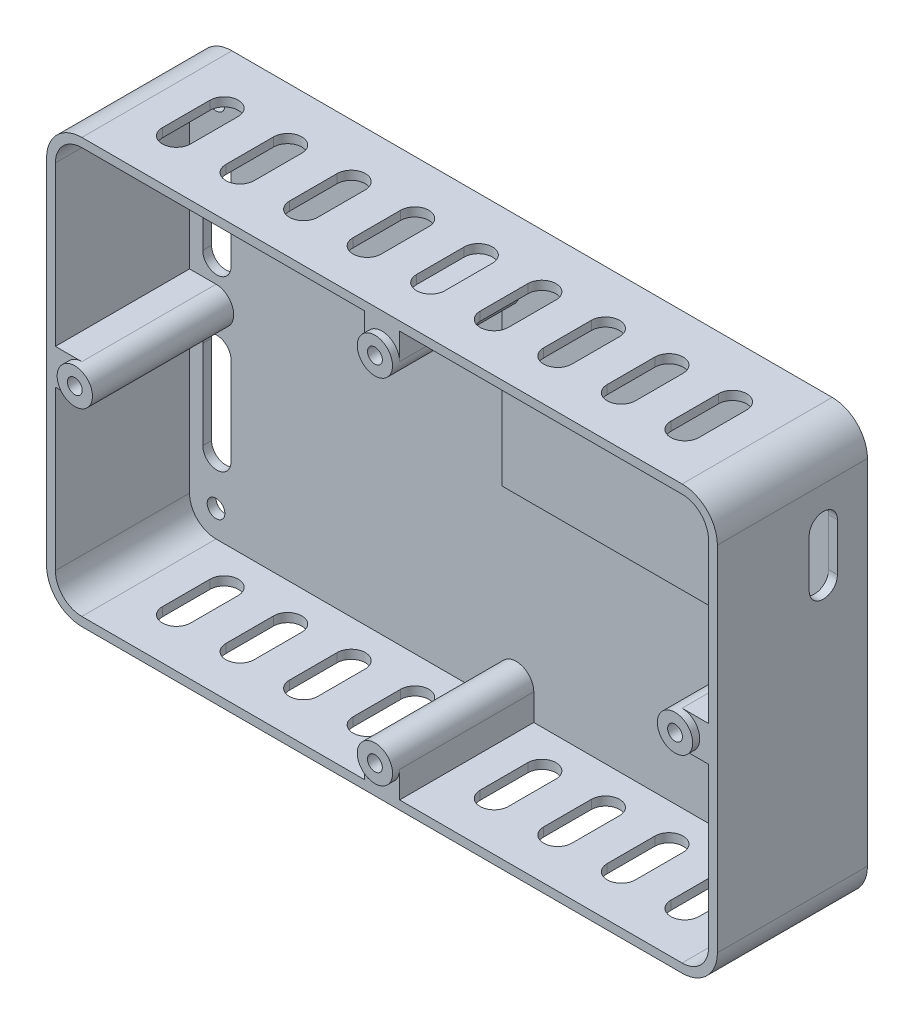
from build123d import *

# Parameters (mm, degrees)
SKETCH1_R                    = 5.975914464
SKETCH1_R_2                  = 5.5
BOSS_EXTRUDE1_DEPTH          = 2
BOSS_EXTRUDE2_DEPTH          = 2.5
SKETCH3_R                    = 5
BOSS_EXTRUDE3_DEPTH          = 38
SKETCH5_R                    = 5
BOSS_EXTRUDE4_DEPTH          = 2
CUT_EXTRUDE1_DEPTH           = 5
TAP_DRILL_FOR_M5_TAP2_D      = 4.2
TAP_DRILL_FOR_M5_TAP2_DEPTH  = 20
TAP_DRILL_FOR_M5_TAP2_TIP    = 1.2618073
F_5_0_5_DIAMETER_HOLE1_D     = 5
F_5_0_5_DIAMETER_HOLE1_DEPTH = 2.5
F_5_0_5_DIAMETER_HOLE1_TIP   = 1.502151548
CUT_EXTRUDE7_DEPTH           = 2.5
BOSS_EXTRUDE5_DEPTH          = 4
CUT_EXTRUDE8_DEPTH           = 2.5
CUT_EXTRUDE9_DEPTH           = 2.5


with BuildPart() as part:
    # Sketch1 → Boss-Extrude1 (new body)
    with BuildSketch(Plane.XY):
        with BuildLine():
            ThreePointArc((-95.175936119, -194.891398577), (-92.247003931, -201.962466389), (-85.175936119, -204.891398577))
            Line((-85.175936119, -204.891398577), (84.824063881, -204.891398577))
            ThreePointArc((84.824063881, -204.891398577), (91.895131693, -201.962466389), (94.824063881, -194.891398577))
            Line((94.824063881, -194.891398577), (94.824063881, -94.891398577))
            ThreePointArc((94.824063881, -94.891398577), (91.895131693, -87.820330766), (84.824063881, -84.891398577))
            Line((84.824063881, -84.891398577), (-85.175936119, -84.891398577))
            ThreePointArc((-85.175936119, -84.891398577), (-92.247003931, -87.820330766), (-95.175936119, -94.891398577))
            Line((-95.175936119, -94.891398577), (-95.175936119, -194.891398577))
        make_face()
        with Locations((84.824063881, -194.891398577)):
            Circle(SKETCH1_R, mode=Mode.SUBTRACT)
        with Locations((-85.175936119, -94.891398577)):
            Circle(SKETCH1_R_2, mode=Mode.SUBTRACT)
        with BuildLine():
            Line((92.324063881, -94.891398577), (92.324063881, -194.891398577))
            ThreePointArc((92.324063881, -194.891398577), (79.520763022, -189.588097719), (84.824063881, -202.391398577))
            Line((84.824063881, -202.391398577), (-85.175936119, -202.391398577))
            ThreePointArc((-85.175936119, -202.391398577), (-79.87263526, -189.588097719), (-92.675936119, -194.891398577))
            Line((-92.675936119, -194.891398577), (-92.675936119, -94.891398577))
            ThreePointArc((-92.675936119, -94.891398577), (-79.87263526, -100.194699436), (-85.175936119, -87.391398577))
            Line((-85.175936119, -87.391398577), (84.824063881, -87.391398577))
            ThreePointArc((84.824063881, -87.391398577), (79.520763022, -100.194699436), (92.324063881, -94.891398577))
        make_face(mode=Mode.SUBTRACT)
        with Locations((84.824063881, -94.891398577)):
            Circle(SKETCH1_R, mode=Mode.SUBTRACT)
        with Locations((-85.175936119, -194.891398577)):
            Circle(SKETCH1_R, mode=Mode.SUBTRACT)
    extrude(amount=BOSS_EXTRUDE1_DEPTH)

    # Sketch2 → Boss-Extrude2 (add)
    with BuildSketch(Plane.XY.offset(2)):
        with BuildLine():
            Line((-95.175936119, -94.891398577), (-95.175936119, -194.891398577))
            ThreePointArc((-95.175936119, -194.891398577), (-92.247003931, -201.962466389), (-85.175936119, -204.891398577))
            Line((-85.175936119, -204.891398577), (84.824063881, -204.891398577))
            ThreePointArc((84.824063881, -204.891398577), (91.895131693, -201.962466389), (94.824063881, -194.891398577))
            Line((94.824063881, -194.891398577), (94.824063881, -94.891398577))
            ThreePointArc((94.824063881, -94.891398577), (91.895131693, -87.820330766), (84.824063881, -84.891398577))
            Line((84.824063881, -84.891398577), (-85.175936119, -84.891398577))
            ThreePointArc((-85.175936119, -84.891398577), (-92.247003931, -87.820330766), (-95.175936119, -94.891398577))
        make_face()
    extrude(amount=BOSS_EXTRUDE2_DEPTH)

    # Sketch3 → Boss-Extrude3 (add)
    with BuildSketch(Plane.XY.offset(4.5)):
        with BuildLine():
            Line((84.824063881, -84.891398577), (-85.175936119, -84.891398577))
            ThreePointArc((-85.175936119, -84.891398577), (-92.247003931, -87.820330766), (-95.175936119, -94.891398577))
            Line((-95.175936119, -94.891398577), (-95.175936119, -194.891398577))
            ThreePointArc((-95.175936119, -194.891398577), (-92.247003931, -201.962466389), (-85.175936119, -204.891398577))
            Line((-85.175936119, -204.891398577), (84.824063881, -204.891398577))
            ThreePointArc((84.824063881, -204.891398577), (91.895131693, -201.962466389), (94.824063881, -194.891398577))
            Line((94.824063881, -194.891398577), (94.824063881, -94.891398577))
            ThreePointArc((94.824063881, -94.891398577), (91.895131693, -87.820330766), (84.824063881, -84.891398577))
        make_face()
        with BuildLine():
            ThreePointArc((92.324063881, -94.891398577), (90.12736474, -89.588097719), (84.824063881, -87.391398577))
            Line((84.824063881, -87.391398577), (-85.175936119, -87.391398577))
            ThreePointArc((-85.175936119, -87.391398577), (-90.479236978, -89.588097719), (-92.675936119, -94.891398577))
            Line((-92.675936119, -94.891398577), (-92.675936119, -194.891398577))
            ThreePointArc((-92.675936119, -194.891398577), (-90.479236978, -200.194699436), (-85.175936119, -202.391398577))
            Line((-85.175936119, -202.391398577), (84.824063881, -202.391398577))
            ThreePointArc((84.824063881, -202.391398577), (90.12736474, -200.194699436), (92.324063881, -194.891398577))
            Line((92.324063881, -194.891398577), (92.324063881, -94.891398577))
        make_face(mode=Mode.SUBTRACT)
        with BuildLine():
            Line((4.824063881, -87.391398577), (-5.175936119, -87.391398577))
            Line((-5.175936119, -87.391398577), (-5.175936119, -94.891398577))
            ThreePointArc((-5.175936119, -94.891398577), (-0.175936119, -89.891398577), (4.824063881, -94.891398577))
            Line((4.824063881, -94.891398577), (4.824063881, -87.391398577))
        make_face()
        with Locations((-0.175936119, -94.891398577)):
            Circle(SKETCH3_R)
        with Locations((84.824063881, -144.891398577)):
            Circle(SKETCH3_R)
        with BuildLine():
            Line((92.324063881, -149.891398577), (92.324063881, -139.891398577))
            Line((92.324063881, -139.891398577), (84.824063881, -139.891398577))
            ThreePointArc((84.824063881, -139.891398577), (88.359597787, -141.355864672), (89.824063881, -144.891398577))
            ThreePointArc((89.824063881, -144.891398577), (88.359597787, -148.426932483), (84.824063881, -149.891398577))
            Line((84.824063881, -149.891398577), (92.324063881, -149.891398577))
        make_face()
        with Locations((-0.175936119, -194.891398577)):
            Circle(SKETCH3_R)
        with BuildLine():
            Line((-5.175936119, -194.891398577), (-5.175936119, -202.391398577))
            Line((-5.175936119, -202.391398577), (4.824063881, -202.391398577))
            Line((4.824063881, -202.391398577), (4.824063881, -194.891398577))
            ThreePointArc((4.824063881, -194.891398577), (-0.175936119, -199.891398577), (-5.175936119, -194.891398577))
        make_face()
        with BuildLine():
            Line((-85.175936119, -139.891398577), (-92.675936119, -139.891398577))
            Line((-92.675936119, -139.891398577), (-92.675936119, -149.891398577))
            Line((-92.675936119, -149.891398577), (-85.175936119, -149.891398577))
            ThreePointArc((-85.175936119, -149.891398577), (-90.175936119, -144.891398577), (-85.175936119, -139.891398577))
        make_face()
        with Locations((-85.175936119, -144.891398577)):
            Circle(SKETCH3_R)
    extrude(amount=BOSS_EXTRUDE3_DEPTH)

    # Sketch5 → Boss-Extrude4 (add)
    with BuildSketch(Plane.XY.offset(42.5)):
        with Locations((-85.175936119, -144.891398577)):
            Circle(SKETCH5_R)
        with Locations((-0.175936119, -94.891398577)):
            Circle(SKETCH5_R)
        with Locations((84.824063881, -144.891398577)):
            Circle(SKETCH5_R)
        with Locations((-0.175936119, -194.891398577)):
            Circle(SKETCH5_R)
    extrude(amount=BOSS_EXTRUDE4_DEPTH)

    # Sketch6 → Cut-Extrude1 (cut)
    with BuildSketch(Plane.XY.offset(4.5)):
        with BuildLine():
            Line((-80.93748893, -181.361482413), (-80.93748893, -156.297951813))
            ThreePointArc((-80.93748893, -156.297951813), (-84.93748893, -152.297951813), (-88.93748893, -156.297951813))
            Line((-88.93748893, -156.297951813), (-88.93748893, -181.361482413))
            ThreePointArc((-88.93748893, -181.361482413), (-84.93748893, -185.361482413), (-80.93748893, -181.361482413))
        make_face()
        with BuildLine():
            Line((-80.93748893, -133.484845342), (-80.93748893, -108.421314742))
            ThreePointArc((-80.93748893, -108.421314742), (-84.93748893, -104.421314742), (-88.93748893, -108.421314742))
            Line((-88.93748893, -108.421314742), (-88.93748893, -133.484845342))
            ThreePointArc((-88.93748893, -133.484845342), (-84.93748893, -137.484845342), (-80.93748893, -133.484845342))
        make_face()
    extrude(amount=-CUT_EXTRUDE1_DEPTH, mode=Mode.SUBTRACT)

    # Tap Drill for M5 Tap2
    with Locations(Plane.XY.offset(44.5)):
        with Locations((-0.175936119, -94.891398577), (-85.175936119, -144.891398577), (84.824063881, -144.891398577), (-0.175936119, -194.891398577)):
            Hole(TAP_DRILL_FOR_M5_TAP2_D / 2, depth=TAP_DRILL_FOR_M5_TAP2_DEPTH)
            with Locations((0, 0, -(TAP_DRILL_FOR_M5_TAP2_DEPTH + TAP_DRILL_FOR_M5_TAP2_TIP / 2))):  # 118° drill point
                Cone(0, TAP_DRILL_FOR_M5_TAP2_D / 2, TAP_DRILL_FOR_M5_TAP2_TIP, mode=Mode.SUBTRACT)

    # Ø5.0 (5) Diameter Hole1
    with Locations(Plane.XY.offset(4.5)):
        with Locations((-85.175936119, -94.891398577), (-85.175936119, -194.891398577), (84.824063881, -194.891398577), (84.824063881, -94.891398577)):
            Hole(F_5_0_5_DIAMETER_HOLE1_D / 2, depth=F_5_0_5_DIAMETER_HOLE1_DEPTH)
            with Locations((0, 0, -(F_5_0_5_DIAMETER_HOLE1_DEPTH + F_5_0_5_DIAMETER_HOLE1_TIP / 2))):  # 118° drill point
                Cone(0, F_5_0_5_DIAMETER_HOLE1_D / 2, F_5_0_5_DIAMETER_HOLE1_TIP, mode=Mode.SUBTRACT)

    # Sketch24 → Cut-Extrude7 (cut)
    with BuildSketch(Plane(origin=(94.824063881, -110.067334696, 0), x_dir=(0, -1, 0), z_dir=(-1, 0, 0))):
        with BuildLine():
            Line((-4.425936119, 8.5), (9.074063881, 8.5))
            ThreePointArc((9.074063881, 8.5), (13.074063881, 12.5), (9.074063881, 16.5))
            Line((9.074063881, 16.5), (-4.425936119, 16.5))
            ThreePointArc((-4.425936119, 16.5), (-8.425936119, 12.5), (-4.425936119, 8.5))
        make_face()
    extrude(amount=CUT_EXTRUDE7_DEPTH, mode=Mode.SUBTRACT)

    # Sketch31 → Cut-Extrude8 (cut)
    with BuildSketch(Plane.XZ.offset(204.891398577)):
        with BuildLine():
            Line((-68.175936119, 28.703996904), (-68.175936119, 15.203996904))
            ThreePointArc((-68.175936119, 15.203996904), (-72.175936119, 11.203996904), (-76.175936119, 15.203996904))
            Line((-76.175936119, 15.203996904), (-76.175936119, 28.703996904))
            ThreePointArc((-76.175936119, 28.703996904), (-72.175936119, 32.703996904), (-68.175936119, 28.703996904))
        make_face()
        with BuildLine():
            Line((-50.175936119, 28.703996904), (-50.175936119, 15.203996904))
            ThreePointArc((-50.175936119, 15.203996904), (-54.175936119, 11.203996904), (-58.175936119, 15.203996904))
            Line((-58.175936119, 15.203996904), (-58.175936119, 28.703996904))
            ThreePointArc((-58.175936119, 28.703996904), (-54.175936119, 32.703996904), (-50.175936119, 28.703996904))
        make_face()
        with BuildLine():
            Line((-32.175936119, 28.703996904), (-32.175936119, 15.203996904))
            ThreePointArc((-32.175936119, 15.203996904), (-36.175936119, 11.203996904), (-40.175936119, 15.203996904))
            Line((-40.175936119, 15.203996904), (-40.175936119, 28.703996904))
            ThreePointArc((-40.175936119, 28.703996904), (-36.175936119, 32.703996904), (-32.175936119, 28.703996904))
        make_face()
        with BuildLine():
            Line((-14.175936119, 28.703996904), (-14.175936119, 15.203996904))
            ThreePointArc((-14.175936119, 15.203996904), (-18.175936119, 11.203996904), (-22.175936119, 15.203996904))
            Line((-22.175936119, 15.203996904), (-22.175936119, 28.703996904))
            ThreePointArc((-22.175936119, 28.703996904), (-18.175936119, 32.703996904), (-14.175936119, 28.703996904))
        make_face()
        with BuildLine():
            Line((3.824063881, 28.703996904), (3.824063881, 15.203996904))
            ThreePointArc((3.824063881, 15.203996904), (-0.175936119, 11.203996904), (-4.175936119, 15.203996904))
            Line((-4.175936119, 15.203996904), (-4.175936119, 28.703996904))
            ThreePointArc((-4.175936119, 28.703996904), (-0.175936119, 32.703996904), (3.824063881, 28.703996904))
        make_face()
        with BuildLine():
            Line((21.824063881, 28.703996904), (21.824063881, 15.203996904))
            ThreePointArc((21.824063881, 15.203996904), (17.824063881, 11.203996904), (13.824063881, 15.203996904))
            Line((13.824063881, 15.203996904), (13.824063881, 28.703996904))
            ThreePointArc((13.824063881, 28.703996904), (17.824063881, 32.703996904), (21.824063881, 28.703996904))
        make_face()
        with BuildLine():
            Line((39.824063881, 28.703996904), (39.824063881, 15.203996904))
            ThreePointArc((39.824063881, 15.203996904), (35.824063881, 11.203996904), (31.824063881, 15.203996904))
            Line((31.824063881, 15.203996904), (31.824063881, 28.703996904))
            ThreePointArc((31.824063881, 28.703996904), (35.824063881, 32.703996904), (39.824063881, 28.703996904))
        make_face()
        with BuildLine():
            Line((57.824063881, 28.703996904), (57.824063881, 15.203996904))
            ThreePointArc((57.824063881, 15.203996904), (53.824063881, 11.203996904), (49.824063881, 15.203996904))
            Line((49.824063881, 15.203996904), (49.824063881, 28.703996904))
            ThreePointArc((49.824063881, 28.703996904), (53.824063881, 32.703996904), (57.824063881, 28.703996904))
        make_face()
        with BuildLine():
            Line((75.824063881, 28.703996904), (75.824063881, 15.203996904))
            ThreePointArc((75.824063881, 15.203996904), (71.824063881, 11.203996904), (67.824063881, 15.203996904))
            Line((67.824063881, 15.203996904), (67.824063881, 28.703996904))
            ThreePointArc((67.824063881, 28.703996904), (71.824063881, 32.703996904), (75.824063881, 28.703996904))
        make_face()
    extrude(amount=-CUT_EXTRUDE8_DEPTH, mode=Mode.SUBTRACT)

    # Sketch32 → Cut-Extrude9 (cut)
    with BuildSketch(Plane(origin=(0, -84.891398577, 0), x_dir=(1, 0, 0), z_dir=(0, 1, 0))):
        with BuildLine():
            Line((67.824063881, -28.703996904), (67.824063881, -15.203996904))
            ThreePointArc((67.824063881, -15.203996904), (71.824063881, -11.203996904), (75.824063881, -15.203996904))
            Line((75.824063881, -15.203996904), (75.824063881, -28.703996904))
            ThreePointArc((75.824063881, -28.703996904), (71.824063881, -32.703996904), (67.824063881, -28.703996904))
        make_face()
        with BuildLine():
            Line((49.824063881, -28.703996904), (49.824063881, -15.203996904))
            ThreePointArc((49.824063881, -15.203996904), (53.824063881, -11.203996904), (57.824063881, -15.203996904))
            Line((57.824063881, -15.203996904), (57.824063881, -28.703996904))
            ThreePointArc((57.824063881, -28.703996904), (53.824063881, -32.703996904), (49.824063881, -28.703996904))
        make_face()
        with BuildLine():
            Line((31.824063881, -28.703996904), (31.824063881, -15.203996904))
            ThreePointArc((31.824063881, -15.203996904), (35.824063881, -11.203996904), (39.824063881, -15.203996904))
            Line((39.824063881, -15.203996904), (39.824063881, -28.703996904))
            ThreePointArc((39.824063881, -28.703996904), (35.824063881, -32.703996904), (31.824063881, -28.703996904))
        make_face()
        with BuildLine():
            Line((13.824063881, -28.703996904), (13.824063881, -15.203996904))
            ThreePointArc((13.824063881, -15.203996904), (17.824063881, -11.203996904), (21.824063881, -15.203996904))
            Line((21.824063881, -15.203996904), (21.824063881, -28.703996904))
            ThreePointArc((21.824063881, -28.703996904), (17.824063881, -32.703996904), (13.824063881, -28.703996904))
        make_face()
        with BuildLine():
            Line((-4.175936119, -28.703996904), (-4.175936119, -15.203996904))
            ThreePointArc((-4.175936119, -15.203996904), (-0.175936119, -11.203996904), (3.824063881, -15.203996904))
            Line((3.824063881, -15.203996904), (3.824063881, -28.703996904))
            ThreePointArc((3.824063881, -28.703996904), (-0.175936119, -32.703996904), (-4.175936119, -28.703996904))
        make_face()
        with BuildLine():
            Line((-22.175936119, -28.703996904), (-22.175936119, -15.203996904))
            ThreePointArc((-22.175936119, -15.203996904), (-18.175936119, -11.203996904), (-14.175936119, -15.203996904))
            Line((-14.175936119, -15.203996904), (-14.175936119, -28.703996904))
            ThreePointArc((-14.175936119, -28.703996904), (-18.175936119, -32.703996904), (-22.175936119, -28.703996904))
        make_face()
        with BuildLine():
            Line((-40.175936119, -28.703996904), (-40.175936119, -15.203996904))
            ThreePointArc((-40.175936119, -15.203996904), (-36.175936119, -11.203996904), (-32.175936119, -15.203996904))
            Line((-32.175936119, -15.203996904), (-32.175936119, -28.703996904))
            ThreePointArc((-32.175936119, -28.703996904), (-36.175936119, -32.703996904), (-40.175936119, -28.703996904))
        make_face()
        with BuildLine():
            Line((-58.175936119, -28.703996904), (-58.175936119, -15.203996904))
            ThreePointArc((-58.175936119, -15.203996904), (-54.175936119, -11.203996904), (-50.175936119, -15.203996904))
            Line((-50.175936119, -15.203996904), (-50.175936119, -28.703996904))
            ThreePointArc((-50.175936119, -28.703996904), (-54.175936119, -32.703996904), (-58.175936119, -28.703996904))
        make_face()
        with BuildLine():
            Line((-76.175936119, -28.703996904), (-76.175936119, -15.203996904))
            ThreePointArc((-76.175936119, -15.203996904), (-72.175936119, -11.203996904), (-68.175936119, -15.203996904))
            Line((-68.175936119, -15.203996904), (-68.175936119, -28.703996904))
            ThreePointArc((-68.175936119, -28.703996904), (-72.175936119, -32.703996904), (-76.175936119, -28.703996904))
        make_face()
    extrude(amount=-CUT_EXTRUDE9_DEPTH, mode=Mode.SUBTRACT)


with BuildPart() as body_2:
    # Sketch25 → Boss-Extrude5 (new body)
    with BuildSketch(Plane.XY.offset(4.5)):
        with BuildLine():
            Line((84.824063881, -87.391398577), (4.824063881, -87.391398577))
            Line((4.824063881, -87.391398577), (4.824063881, -94.891398577))
            ThreePointArc((4.824063881, -94.891398577), (3.359597787, -98.426932483), (-0.175936119, -99.891398577))
            Line((-0.175936119, -99.891398577), (-0.175936119, -144.891398577))
            Line((-0.175936119, -144.891398577), (79.824063881, -144.891398577))
            ThreePointArc((79.824063881, -144.891398577), (81.288529975, -141.355864672), (84.824063881, -139.891398577))
            Line((84.824063881, -139.891398577), (92.324063881, -139.891398577))
            Line((92.324063881, -139.891398577), (92.324063881, -94.891398577))
            ThreePointArc((92.324063881, -94.891398577), (79.520763022, -100.194699436), (84.824063881, -87.391398577))
        make_face()
    extrude(amount=BOSS_EXTRUDE5_DEPTH)


solid = Compound([part.part, body_2.part])
